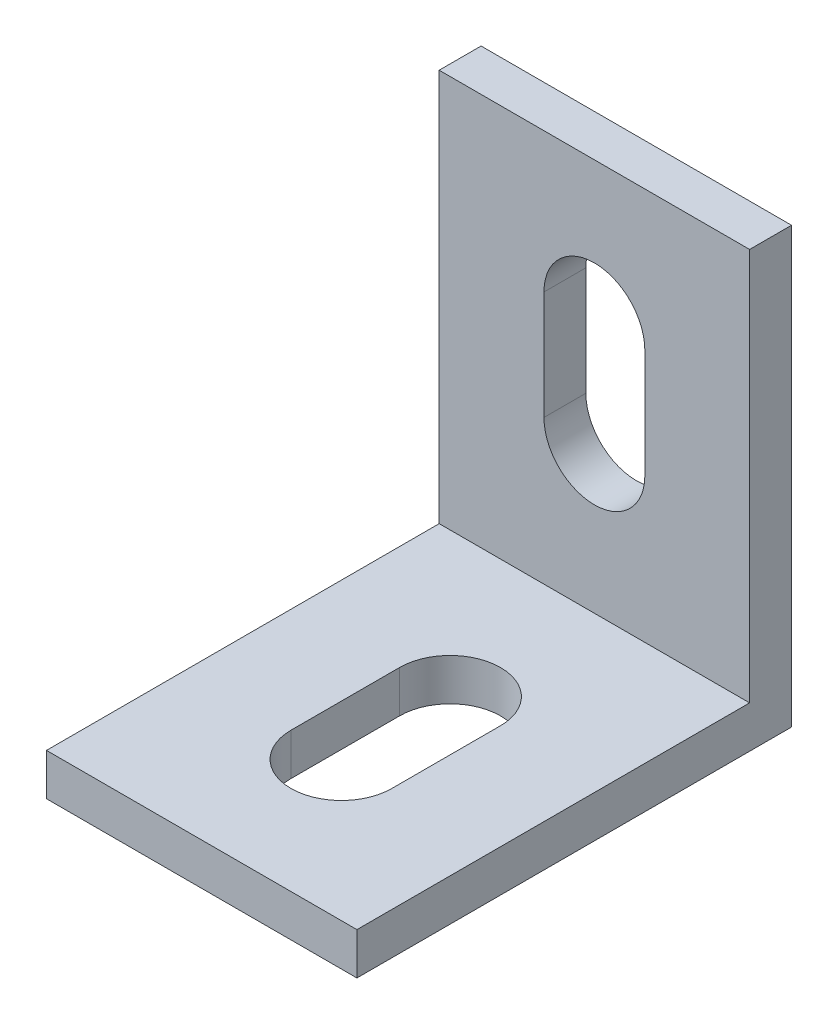
from build123d import *

# Parameters (mm, degrees)
SKETCH_1_W      = 20
SKETCH_1_H      = 28
EXTRUDE_1_DEPTH = 2.7
SKETCH_2_W      = 20
SKETCH_2_H      = 28
EXTRUDE_2_DEPTH = 2.7


with BuildPart() as part:
    # 草图1 → 凸台-拉伸1 (new body)
    with BuildSketch(Plane(origin=(0, 0, 0), x_dir=(1, 0, 0), z_dir=(0, 1, 0))):
        Rectangle(SKETCH_1_W, SKETCH_1_H)
        with BuildLine():
            Line((3.25, 2), (3.25, -5))
            ThreePointArc((3.25, -5), (0, -8.25), (-3.25, -5))
            Line((-3.25, -5), (-3.25, 2))
            ThreePointArc((-3.25, 2), (0, 5.25), (3.25, 2))
        make_face(mode=Mode.SUBTRACT)
    extrude(amount=EXTRUDE_1_DEPTH)

    # 草图2 → 凸台-拉伸2 (add)
    with BuildSketch(Plane(origin=(0, 0, -14), x_dir=(-1, 0, 0), z_dir=(0, 0, -1))):
        with Locations((0, 14)):
            Rectangle(SKETCH_2_W, SKETCH_2_H)
        with BuildLine():
            Line((-3.25, 12), (-3.25, 19))
            ThreePointArc((-3.25, 19), (0, 22.25), (3.25, 19))
            Line((3.25, 19), (3.25, 12))
            ThreePointArc((3.25, 12), (0, 8.75), (-3.25, 12))
        make_face(mode=Mode.SUBTRACT)
    extrude(amount=-EXTRUDE_2_DEPTH)


solid = part.part
